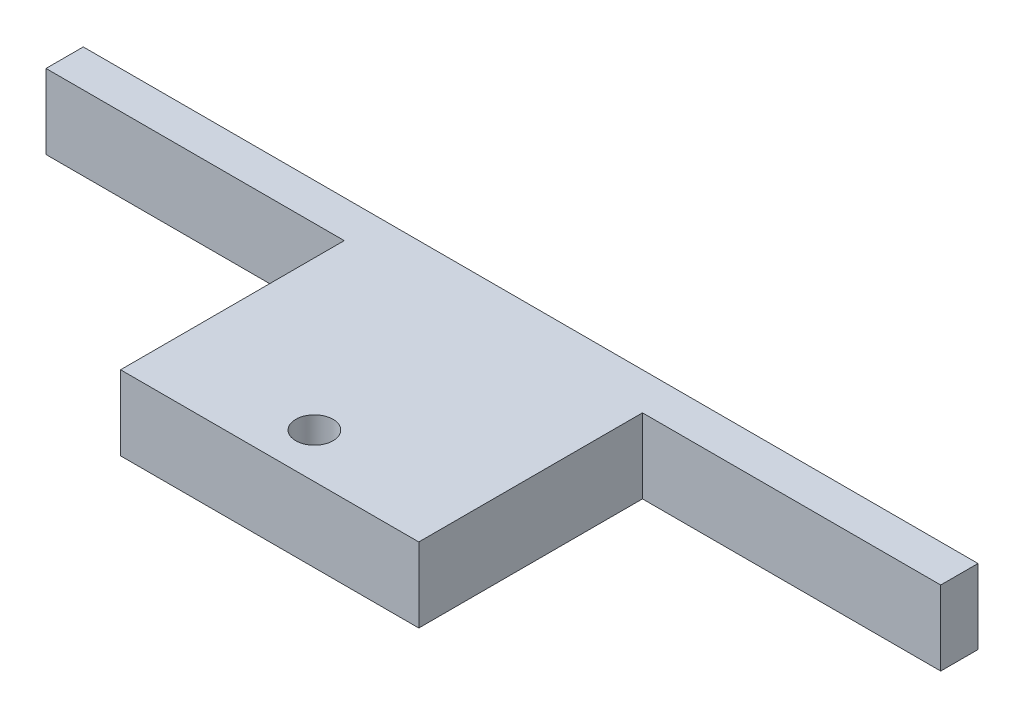
from build123d import *

# Parameters (mm, degrees)
SKETCH1_W                    = 152.4
SKETCH1_H                    = 114.3
BOSS_EXTRUDE1_DEPTH          = 38.1
SKETCH2_W                    = 457.2
SKETCH2_H                    = 38.1
BOSS_EXTRUDE2_DEPTH          = 19.05
F_96_0_0063_DIAMETER_HOLE1_D = 19.05


with BuildPart() as part:
    # Sketch1 → Boss-Extrude1 (new body)
    with BuildSketch(Plane(origin=(0, 0, 0), x_dir=(1, 0, 0), z_dir=(0, 1, 0))):
        with Locations((76.2, 57.15)):
            Rectangle(SKETCH1_W, SKETCH1_H)
    extrude(amount=BOSS_EXTRUDE1_DEPTH)

    # Sketch2 → Boss-Extrude2 (add)
    with BuildSketch(Plane(origin=(0, 0, -114.3), x_dir=(-1, 0, 0), z_dir=(0, 0, -1))):
        with Locations((-76.2, 19.05)):
            Rectangle(SKETCH2_W, SKETCH2_H)
    extrude(amount=BOSS_EXTRUDE2_DEPTH)

    # #96 (0.0063) Diameter Hole1 (through all)
    with Locations(Plane(origin=(76.2, 0, -22.86), x_dir=(0, 0, -1), z_dir=(0, -1, 0))):
        with Locations((0, 0)):
            Hole(F_96_0_0063_DIAMETER_HOLE1_D / 2)


solid = part.part
